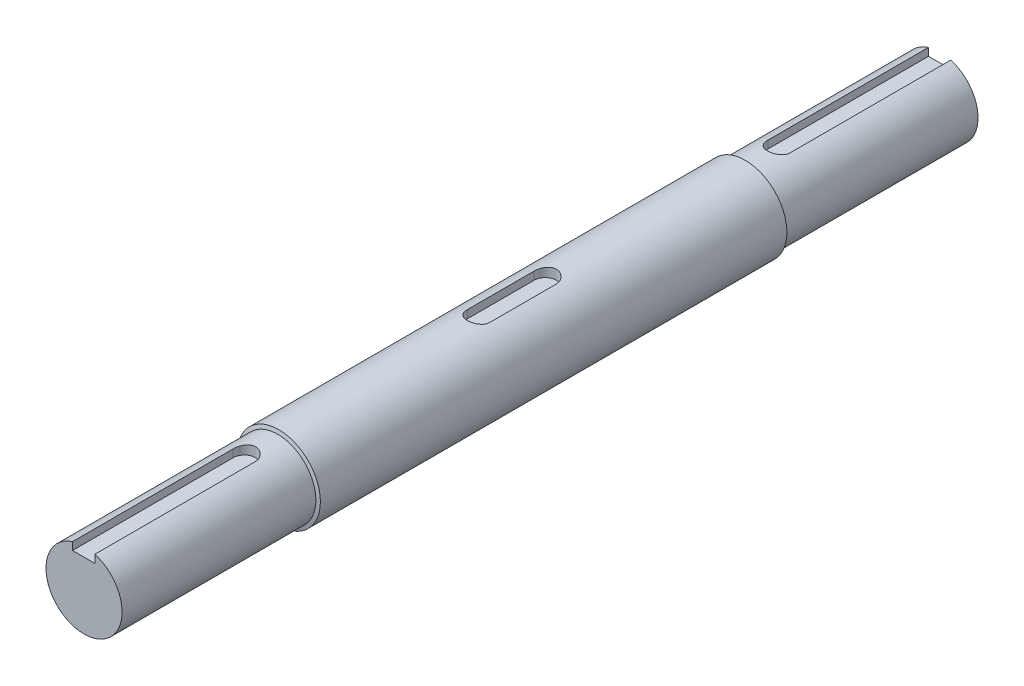
from build123d import *

# Parameters (mm, degrees)
SKETCH1_R           = 8.75
BOSS_EXTRUDE1_DEPTH = 180
SKETCH2_R           = 8.75
SKETCH2_R_2         = 8
CUT_EXTRUDE1_DEPTH  = 40.95
CUT_EXTRUDE2_DEPTH  = 33.8
CUT_EXTRUDE3_DEPTH  = 33.8
CUT_EXTRUDE4_DEPTH  = 33.8
SKETCH7_R           = 8.75
BOSS_EXTRUDE2_DEPTH = 7.8
SKETCH9_R           = 8.75
BOSS_EXTRUDE3_DEPTH = 0.3
BOSS_EXTRUDE3_TAPER = 75


with BuildPart() as part:
    # Sketch1 → Boss-Extrude1 (new body)
    with BuildSketch(Plane.XY):
        Circle(SKETCH1_R)
    extrude(amount=BOSS_EXTRUDE1_DEPTH)

    # Sketch2 → Cut-Extrude1 (cut)
    with BuildSketch(Plane.XY.offset(180)):
        Circle(SKETCH2_R)
        Circle(SKETCH2_R_2, mode=Mode.SUBTRACT)
    cut_extrude1 = extrude(amount=-CUT_EXTRUDE1_DEPTH, mode=Mode.SUBTRACT)

    # Sketch3 → Cut-Extrude2 (cut)
    with BuildSketch(Plane.XY.offset(180)):
        with BuildLine():
            Line((-2.423043871, 5.999555366), (2.276956129, 5.999555366))
            Line((2.276956129, 5.999555366), (2.276956129, 7.669124513))
            ThreePointArc((2.276956129, 7.669124513), (-0.076415462, 7.999635034), (-2.423043871, 7.62422838))
            Line((-2.423043871, 7.62422838), (-2.423043871, 5.999555366))
        make_face()
    cut_extrude2 = extrude(amount=-CUT_EXTRUDE2_DEPTH, mode=Mode.SUBTRACT)

    # Sketch4 → Cut-Extrude3 (cut)
    with BuildSketch(Plane(origin=(0, 5.999555366, 0), x_dir=(1, 0, 0), z_dir=(0, 1, 0))):
        with BuildLine():
            Line((-2.423043871, -146.2), (2.276956129, -146.2))
            ThreePointArc((2.276956129, -146.2), (-0.073043871, -143.85), (-2.423043871, -146.2))
        make_face()
    cut_extrude3 = extrude(amount=CUT_EXTRUDE3_DEPTH, mode=Mode.SUBTRACT)

    # Mirror1: Cut-Extrude1, Cut-Extrude2, Cut-Extrude3 across plane
    add(cut_extrude1.mirror(Plane.XY.offset(90)), mode=Mode.SUBTRACT)
    add(cut_extrude2.mirror(Plane.XY.offset(90)), mode=Mode.SUBTRACT)
    add(cut_extrude3.mirror(Plane.XY.offset(90)), mode=Mode.SUBTRACT)

    # Sketch6 → Cut-Extrude4 (cut)
    with BuildSketch(Plane(origin=(0, 6.75, 0), x_dir=(1, 0, 0), z_dir=(0, 1, 0))):
        with BuildLine():
            Line((-2.35, -97), (-2.35, -83))
            ThreePointArc((-2.35, -83), (0, -80.65), (2.35, -83))
            Line((2.35, -83), (2.35, -97))
            ThreePointArc((2.35, -97), (0, -99.35), (-2.35, -97))
        make_face()
    extrude(amount=CUT_EXTRUDE4_DEPTH, mode=Mode.SUBTRACT)

    # Sketch7 → Boss-Extrude2 (add)
    with BuildSketch(Plane(origin=(0, 0, 40.95), x_dir=(-1, 0, 0), z_dir=(0, 0, -1))):
        Circle(SKETCH7_R)
    extrude(amount=-BOSS_EXTRUDE2_DEPTH)

    # Sketch9 → Boss-Extrude3 (add)
    with BuildSketch(Plane(origin=(0, 0, 40.95), x_dir=(-1, 0, 0), z_dir=(0, 0, -1))):
        Circle(SKETCH9_R)
    boss_extrude3 = extrude(amount=BOSS_EXTRUDE3_DEPTH, taper=BOSS_EXTRUDE3_TAPER)

    # Mirror4: Boss-Extrude3 across plane
    add(boss_extrude3.mirror(Plane.XY.offset(90)))


solid = part.part
